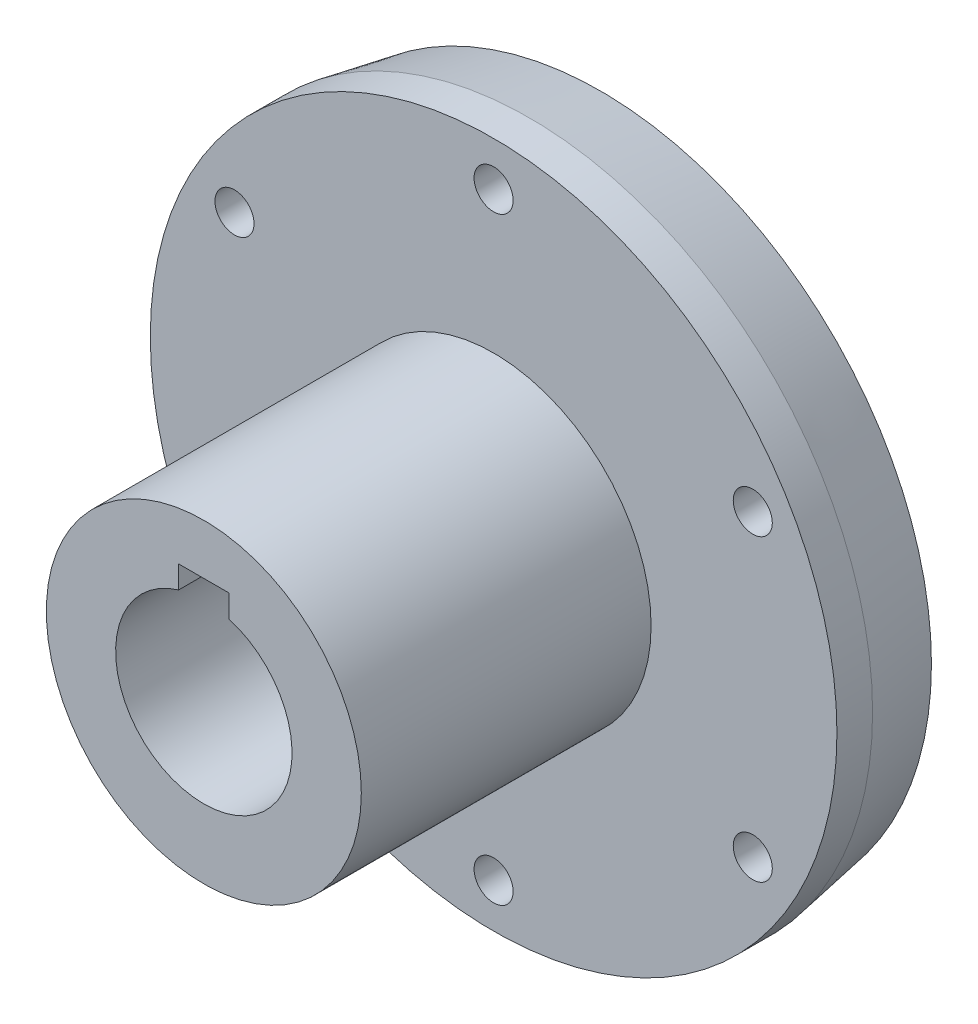
from build123d import *

# Parameters (mm, degrees)
ESQUISSE1_R             = 54.5
BOSS_EXTRU_1_DEPTH      = 17
ESQUISSE5_R             = 25
BOSS_EXTRU_4_DEPTH      = 46
ENL_V_MAT_EXTRU_2_DEPTH = 56
ESQUISSE8_R             = 5.1
ENL_V_MAT_EXTRU_3_DEPTH = 76
ESQUISSE9_R             = 3.1
ENL_V_MAT_EXTRU_4_DEPTH = 76
CHANFREIN1_SIZE         = 2
CHANFREIN1_SIZE2        = 11.342563639


with BuildPart() as part:
    # Esquisse1 → Boss.-Extru.1 (new body)
    with BuildSketch(Plane.XY):
        Circle(ESQUISSE1_R)
    extrude(amount=BOSS_EXTRU_1_DEPTH)

    # Esquisse5 → Boss.-Extru.4 (add)
    with BuildSketch(Plane.XY.offset(17)):
        Circle(ESQUISSE5_R)
    extrude(amount=BOSS_EXTRU_4_DEPTH)

    # Esquisse7 → Enlèv. mat.-Extru.2 (cut)
    with BuildSketch(Plane.XY.offset(63)):
        with BuildLine():
            Line((-4, 17), (-4, 13.416407865))
            ThreePointArc((-4, 13.416407865), (0, -14), (4, 13.416407865))
            Line((4, 13.416407865), (4, 17))
            Line((4, 17), (-4, 17))
        make_face()
    extrude(amount=-ENL_V_MAT_EXTRU_2_DEPTH, mode=Mode.SUBTRACT)

    # Esquisse8 → Enlèv. mat.-Extru.3 (cut)
    with BuildSketch(Plane(origin=(0, 0, 0), x_dir=(-1, 0, 0), z_dir=(0, 0, -1))):
        Circle(ESQUISSE8_R)
    extrude(amount=-ENL_V_MAT_EXTRU_3_DEPTH, mode=Mode.SUBTRACT)

    # Esquisse9 → Enlèv. mat.-Extru.4 (cut)
    with BuildSketch(Plane(origin=(0, 0, 0), x_dir=(-1, 0, 0), z_dir=(0, 0, -1))):
        with Locations((0, 47.5)):
            Circle(ESQUISSE9_R)
        with Locations((41.13620668, 23.75)):
            Circle(ESQUISSE9_R)
        with Locations((41.13620668, -23.75)):
            Circle(ESQUISSE9_R)
        with Locations((0, -47.5)):
            Circle(ESQUISSE9_R)
        with Locations((-41.13620668, -23.75)):
            Circle(ESQUISSE9_R)
        with Locations((-41.13620668, 23.75)):
            Circle(ESQUISSE9_R)
    extrude(amount=-ENL_V_MAT_EXTRU_4_DEPTH, mode=Mode.SUBTRACT)

    # Chanfrein1
    chanfrein1_edges = [part.edges().sort_by_distance(p)[0] for p in [
        (-54.5, 0, 0),
    ]]
    chanfrein1_side = [part.faces().sort_by_distance(p)[0] for p in [
        (-52.958507217, 0, 0),
    ]]
    chamfer(chanfrein1_edges, length=CHANFREIN1_SIZE, length2=CHANFREIN1_SIZE2, reference=chanfrein1_side[0])


solid = part.part
